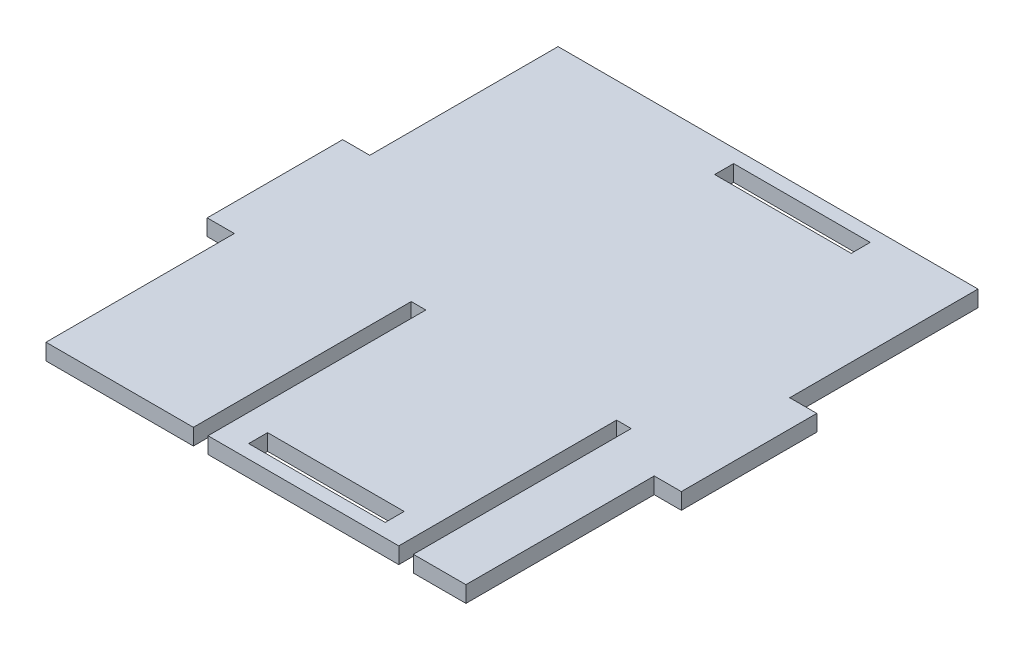
from build123d import *

# Parameters (mm, degrees)
SKETCH1_W           = 50.4
SKETCH1_H           = 7
SKETCH1_W_2         = 10
SKETCH1_H_2         = 50
BOSS_EXTRUDE1_DEPTH = 6


with BuildPart() as part:
    # Sketch1 → Boss-Extrude1 (new body)
    with BuildSketch(Plane(origin=(0, 0, 0), x_dir=(1, 0, 0), z_dir=(0, 1, 0))):
        Polygon((-19.4, 0), (0, 0), (0, 69.5), (0, 119.5), (0, 189), (-155, 189), (-155, 119.5), (-155, 69.5), (-155, 0), (-100.6, 0), (-100.6, 80.4), (-95.2, 80.4), (-95.2, 0), (-75, 0), (-25, 0), (-24.8, 0), (-24.8, 80.4), (-19.4, 80.4), align=None)
        with Locations((-60, 8.5)):
            Rectangle(SKETCH1_W, SKETCH1_H, mode=Mode.SUBTRACT)
        with Locations((-60, 180.5)):
            Rectangle(SKETCH1_W, SKETCH1_H, mode=Mode.SUBTRACT)
        with Locations((-160, 94.5)):
            Rectangle(SKETCH1_W_2, SKETCH1_H_2)
        with Locations((5, 94.5)):
            Rectangle(SKETCH1_W_2, SKETCH1_H_2)
    extrude(amount=BOSS_EXTRUDE1_DEPTH)


solid = part.part
